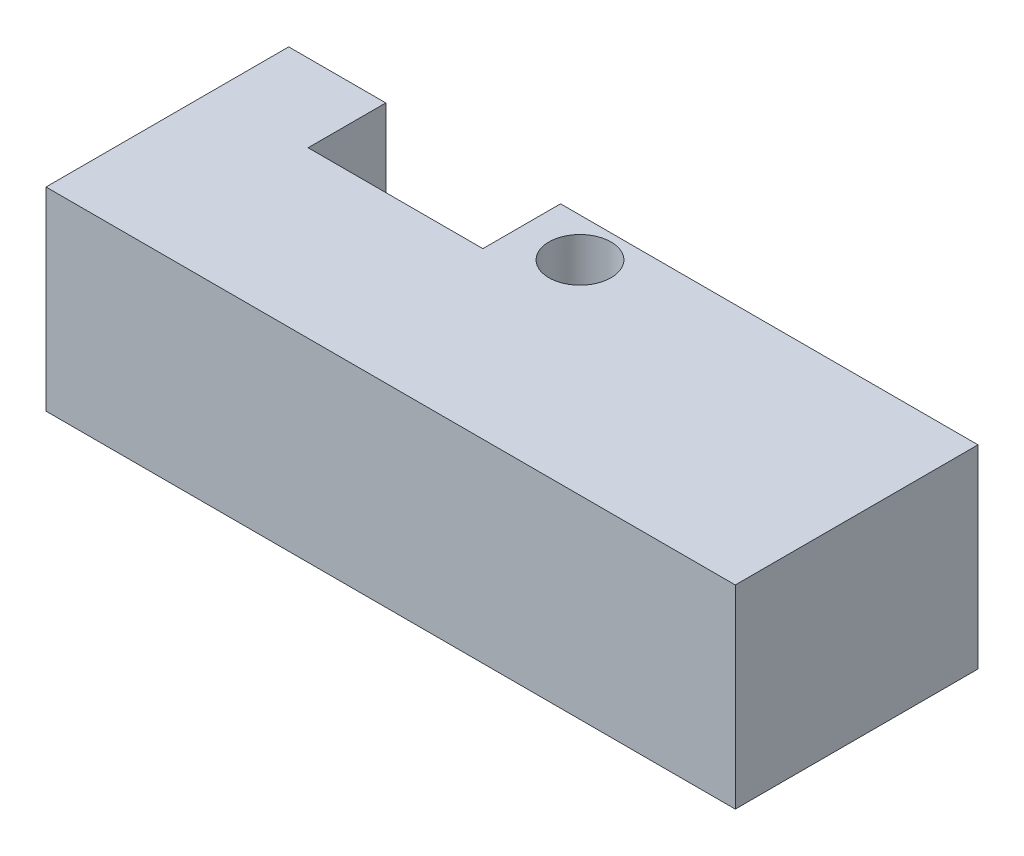
from build123d import *

# Parameters (mm, degrees)
SKETCH1_W                      = 35.5
SKETCH1_H                      = 12.5
BOSS_EXTRUDE1_DEPTH            = 10
SKETCH2_W                      = 25.5
SKETCH2_H                      = 7.5
CUT_EXTRUDE1_DEPTH             = 7.5
SKETCH4_R                      = 1
CUT_EXTRUDE2_DEPTH             = 4
SKETCH6_W                      = 9
SKETCH6_H                      = 2.5
CUT_EXTRUDE3_DEPTH             = 4
CUT_EXTRUDE4_REACH             = 12
SKETCH7_R                      = 1.6
CUT_EXTRUDE4_DIRECTION_2_DEPTH = 1


with BuildPart() as part:
    # Sketch1 → Boss-Extrude1 (new body)
    with BuildSketch(Plane(origin=(0, 0, 0), x_dir=(1, 0, 0), z_dir=(0, 1, 0))):
        Rectangle(SKETCH1_W, SKETCH1_H)
    extrude(amount=BOSS_EXTRUDE1_DEPTH)

    # Sketch2 → Cut-Extrude1 (cut)
    with BuildSketch(Plane.XZ):
        with Locations((0, -2.5)):
            Rectangle(SKETCH2_W, SKETCH2_H)
    extrude(amount=-CUT_EXTRUDE1_DEPTH, mode=Mode.SUBTRACT)

    # Sketch4 → Cut-Extrude2 (cut)
    with BuildSketch(Plane(origin=(0, 0, -6.25), x_dir=(-1, 0, 0), z_dir=(0, 0, -1))):
        with Locations((-14.75, 3)):
            Circle(SKETCH4_R)
        with Locations((14.75, 3)):
            Circle(SKETCH4_R)
    extrude(amount=-CUT_EXTRUDE2_DEPTH, mode=Mode.SUBTRACT)

    # Sketch6 → Cut-Extrude3 (cut)
    with BuildSketch(Plane(origin=(0, 0, -6.25), x_dir=(-1, 0, 0), z_dir=(0, 0, -1))):
        with Locations((8.25, 8.75)):
            Rectangle(SKETCH6_W, SKETCH6_H)
    extrude(amount=-CUT_EXTRUDE3_DEPTH, mode=Mode.SUBTRACT)

    # Sketch7 → Cut-Extrude4 (cut, up to next)
    with BuildSketch(Plane(origin=(0, 10, 0), x_dir=(1, 0, 0), z_dir=(0, 1, 0)), mode=Mode.PRIVATE) as cut_extrude4_sk1:
        with Locations((-0.75, 4.25)):
            Circle(SKETCH7_R)
    cut_extrude4_tool1 = extrude(cut_extrude4_sk1.sketch, amount=-CUT_EXTRUDE4_REACH, mode=Mode.PRIVATE) & part.part
    add(cut_extrude4_tool1.solids().sort_by_distance((-0.75, 10, -4.25))[0], mode=Mode.SUBTRACT)

    # Sketch7 → Cut-Extrude4 direction 2 (cut)
    with BuildSketch(Plane(origin=(0, 10, 0), x_dir=(1, 0, 0), z_dir=(0, 1, 0))):
        with Locations((-0.75, 4.25)):
            Circle(SKETCH7_R)
    extrude(amount=CUT_EXTRUDE4_DIRECTION_2_DEPTH, mode=Mode.SUBTRACT)


solid = part.part
